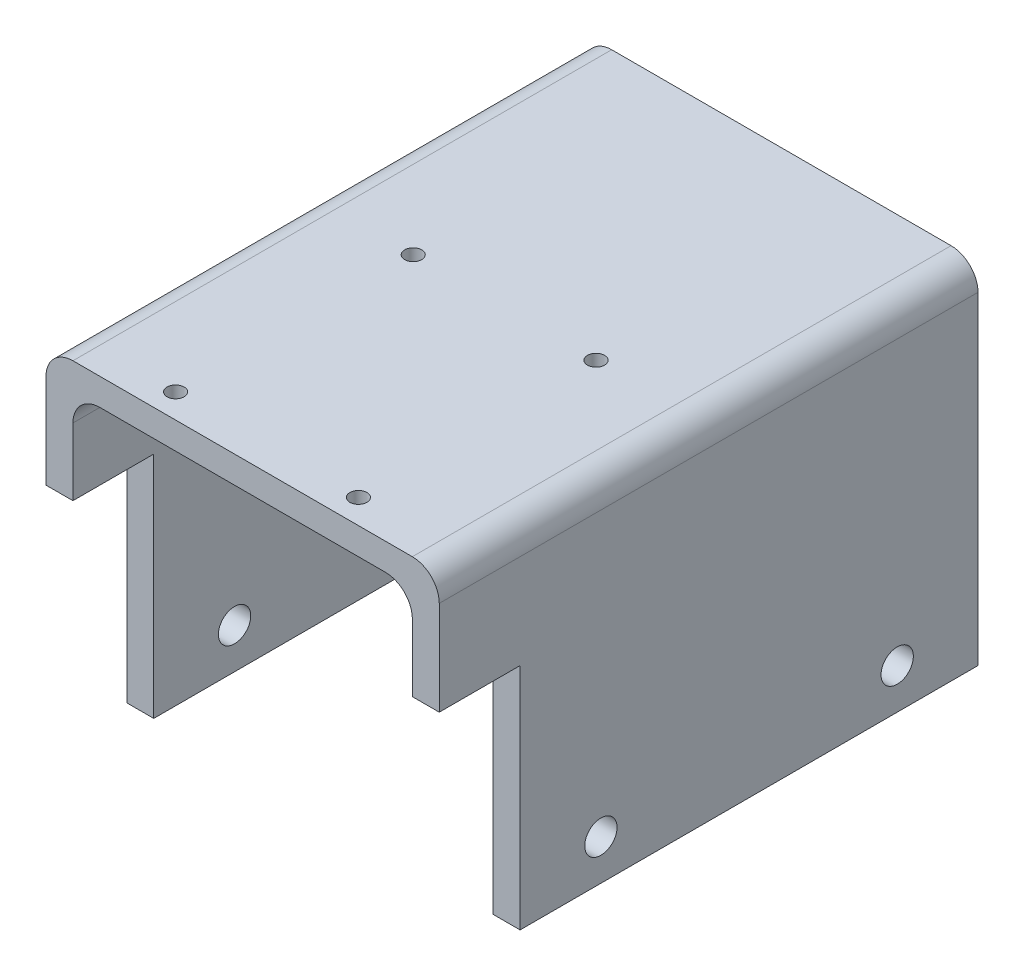
from build123d import *

# Parameters (mm, degrees)
SALIENTE_EXTRUIR1_DEPTH = 200
REDONDEO1_R             = 10
CROQUIS2_R              = 6
CORTAR_EXTRUIR1_DEPTH   = 147
CROQUIS3_W              = 30
CROQUIS3_H              = 85
CORTAR_EXTRUIR2_DEPTH   = 147
CORTAR_EXTRUIR3_REACH   = 132
CROQUIS4_R              = 3.1665


with BuildPart() as part:
    # Croquis1 → Saliente-Extruir1 (new body)
    with BuildSketch(Plane.XY):
        Polygon((-136, 0), (-126, 0), (-126, 120), (0, 120), (0, 0), (10, 0), (10, 130), (-136, 130), align=None)
    extrude(amount=SALIENTE_EXTRUIR1_DEPTH)

    # Redondeo1
    redondeo1_edges = [part.edges().sort_by_distance(p)[0] for p in [
        (-136, 130, 100),
        (10, 130, 100),
        (0, 120, 100),
        (-126, 120, 100),
    ]]
    fillet(redondeo1_edges, radius=REDONDEO1_R)

    # Croquis2 → Cortar-Extruir1 (cut, through all)
    with BuildSketch(Plane(origin=(10, 0, 0), x_dir=(0, 0, -1), z_dir=(1, 0, 0))):
        with Locations((-140, 15)):
            Circle(CROQUIS2_R)
        with Locations((-30, 15)):
            Circle(CROQUIS2_R)
    extrude(amount=-CORTAR_EXTRUIR1_DEPTH, mode=Mode.SUBTRACT)

    # Croquis3 → Cortar-Extruir2 (cut, through all)
    with BuildSketch(Plane(origin=(10, 0, 0), x_dir=(0, 0, -1), z_dir=(1, 0, 0))):
        with Locations((-185, 42.5)):
            Rectangle(CROQUIS3_W, CROQUIS3_H)
    extrude(amount=-CORTAR_EXTRUIR2_DEPTH, mode=Mode.SUBTRACT)

    # Croquis4 → Cortar-Extruir3 (cut, up to next)
    with BuildSketch(Plane(origin=(0, 130, 0), x_dir=(1, 0, 0), z_dir=(0, 1, 0)), mode=Mode.PRIVATE) as cortar_extruir3_sk1:
        with Locations((-96.928, -190.953)):
            Circle(CROQUIS4_R)
    cortar_extruir3_tool1 = extrude(cortar_extruir3_sk1.sketch, amount=-CORTAR_EXTRUIR3_REACH, mode=Mode.PRIVATE) & part.part
    add(cortar_extruir3_tool1.solids().sort_by_distance((-96.928, 130, 190.953))[0], mode=Mode.SUBTRACT)
    # Croquis4 → Cortar-Extruir3 (cut, up to next)
    with BuildSketch(Plane(origin=(0, 130, 0), x_dir=(1, 0, 0), z_dir=(0, 1, 0)), mode=Mode.PRIVATE) as cortar_extruir3_sk2:
        with Locations((-29.072, -190.953)):
            Circle(CROQUIS4_R)
    cortar_extruir3_tool2 = extrude(cortar_extruir3_sk2.sketch, amount=-CORTAR_EXTRUIR3_REACH, mode=Mode.PRIVATE) & part.part
    add(cortar_extruir3_tool2.solids().sort_by_distance((-29.072, 130, 190.953))[0], mode=Mode.SUBTRACT)
    # Croquis4 → Cortar-Extruir3 (cut, up to next)
    with BuildSketch(Plane(origin=(0, 130, 0), x_dir=(1, 0, 0), z_dir=(0, 1, 0)), mode=Mode.PRIVATE) as cortar_extruir3_sk3:
        with Locations((-96.928, -102.741)):
            Circle(CROQUIS4_R)
    cortar_extruir3_tool3 = extrude(cortar_extruir3_sk3.sketch, amount=-CORTAR_EXTRUIR3_REACH, mode=Mode.PRIVATE) & part.part
    add(cortar_extruir3_tool3.solids().sort_by_distance((-96.928, 130, 102.741))[0], mode=Mode.SUBTRACT)
    # Croquis4 → Cortar-Extruir3 (cut, up to next)
    with BuildSketch(Plane(origin=(0, 130, 0), x_dir=(1, 0, 0), z_dir=(0, 1, 0)), mode=Mode.PRIVATE) as cortar_extruir3_sk4:
        with Locations((-29.072, -102.741)):
            Circle(CROQUIS4_R)
    cortar_extruir3_tool4 = extrude(cortar_extruir3_sk4.sketch, amount=-CORTAR_EXTRUIR3_REACH, mode=Mode.PRIVATE) & part.part
    add(cortar_extruir3_tool4.solids().sort_by_distance((-29.072, 130, 102.741))[0], mode=Mode.SUBTRACT)


solid = part.part
